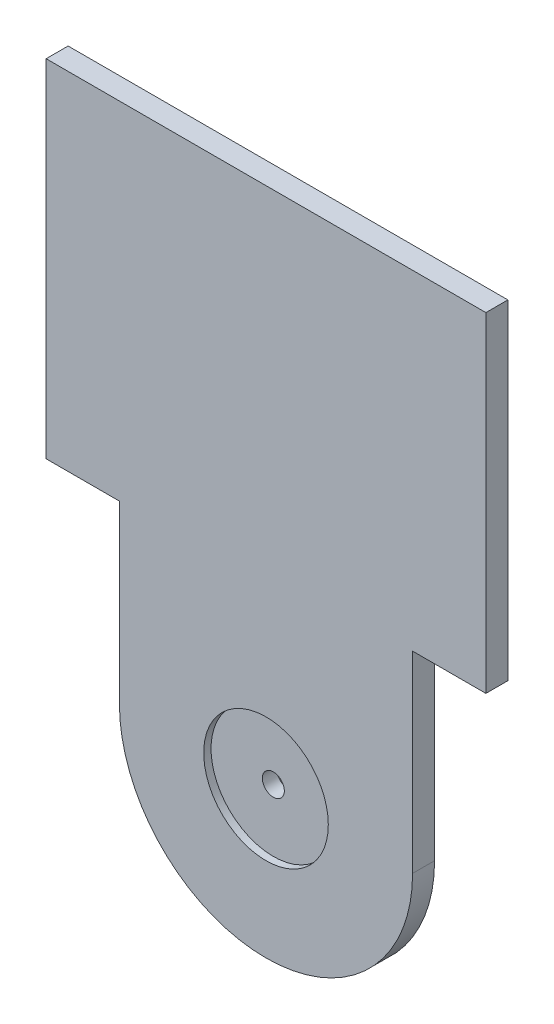
from build123d import *

# Parameters (mm, degrees)
CROQUIS1_R              = 1.5
SALIENTE_EXTRUIR1_DEPTH = 3
CROQUIS2_R              = 8.5
CORTAR_EXTRUIR1_DEPTH   = 1


with BuildPart() as part:
    # Croquis1 → Saliente-Extruir1 (new body)
    with BuildSketch(Plane.XY):
        with BuildLine():
            Line((-113.991811363, 10.970788205), (-113.991811363, 34.958108792))
            Line((-113.991811363, 34.958108792), (-123.991811363, 34.958108792))
            Line((-123.991811363, 34.958108792), (-123.991811363, 82.236637471))
            Line((-123.991811363, 82.236637471), (-63.991811363, 82.236637471))
            Line((-63.991811363, 82.236637471), (-63.991811363, 37.236637471))
            Line((-63.991811363, 37.236637471), (-73.991811363, 37.236637471))
            Line((-73.991811363, 37.236637471), (-73.991811363, 10.970788205))
            ThreePointArc((-73.991811363, 10.970788205), (-93.991811363, -9.029211795), (-113.991811363, 10.970788205))
        make_face()
        with Locations((-93.991811363, 10.970788205)):
            Circle(CROQUIS1_R, mode=Mode.SUBTRACT)
    extrude(amount=SALIENTE_EXTRUIR1_DEPTH)

    # Croquis2 → Cortar-Extruir1 (cut)
    with BuildSketch(Plane.XY.offset(3)):
        with Locations((-93.991811363, 10.970788205)):
            Circle(CROQUIS2_R)
    extrude(amount=-CORTAR_EXTRUIR1_DEPTH, mode=Mode.SUBTRACT)


solid = part.part
